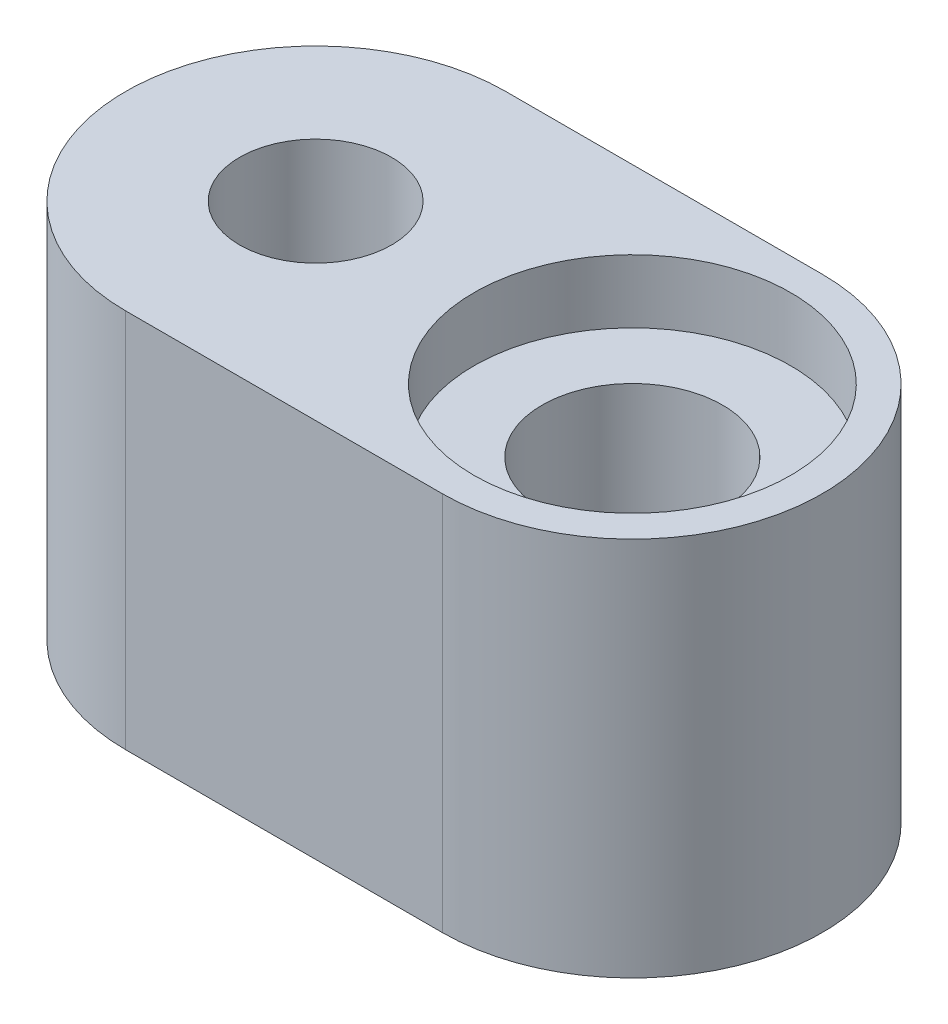
from build123d import *

# Parameters (mm, degrees)
SKETCH_1_R          = 1.425
SKETCH_1_R_2        = 1.2
EXTRUDE_1_DEPTH     = 6
SKETCH_2_R          = 2.5
CUT_EXTRUDE_1_DEPTH = 1


with BuildPart() as part:
    # 草图1 → 凸台-拉伸1 (new body)
    with BuildSketch(Plane(origin=(0, 0, 0), x_dir=(1, 0, 0), z_dir=(0, 1, 0))):
        with BuildLine():
            Line((-2.5, 3), (2.5, 3))
            ThreePointArc((2.5, 3), (5.5, 0), (2.5, -3))
            Line((2.5, -3), (-2.5, -3))
            ThreePointArc((-2.5, -3), (-5.5, 0), (-2.5, 3))
        make_face()
        with Locations((2.5, 0)):
            Circle(SKETCH_1_R, mode=Mode.SUBTRACT)
        with Locations((-2.5, 0)):
            Circle(SKETCH_1_R_2, mode=Mode.SUBTRACT)
    extrude(amount=EXTRUDE_1_DEPTH)

    # 草图2 → 切除-拉伸1 (cut)
    with BuildSketch(Plane(origin=(0, 6, 0), x_dir=(1, 0, 0), z_dir=(0, 1, 0))):
        with Locations((2.5, 0)):
            Circle(SKETCH_2_R)
    extrude(amount=-CUT_EXTRUDE_1_DEPTH, mode=Mode.SUBTRACT)


solid = part.part
